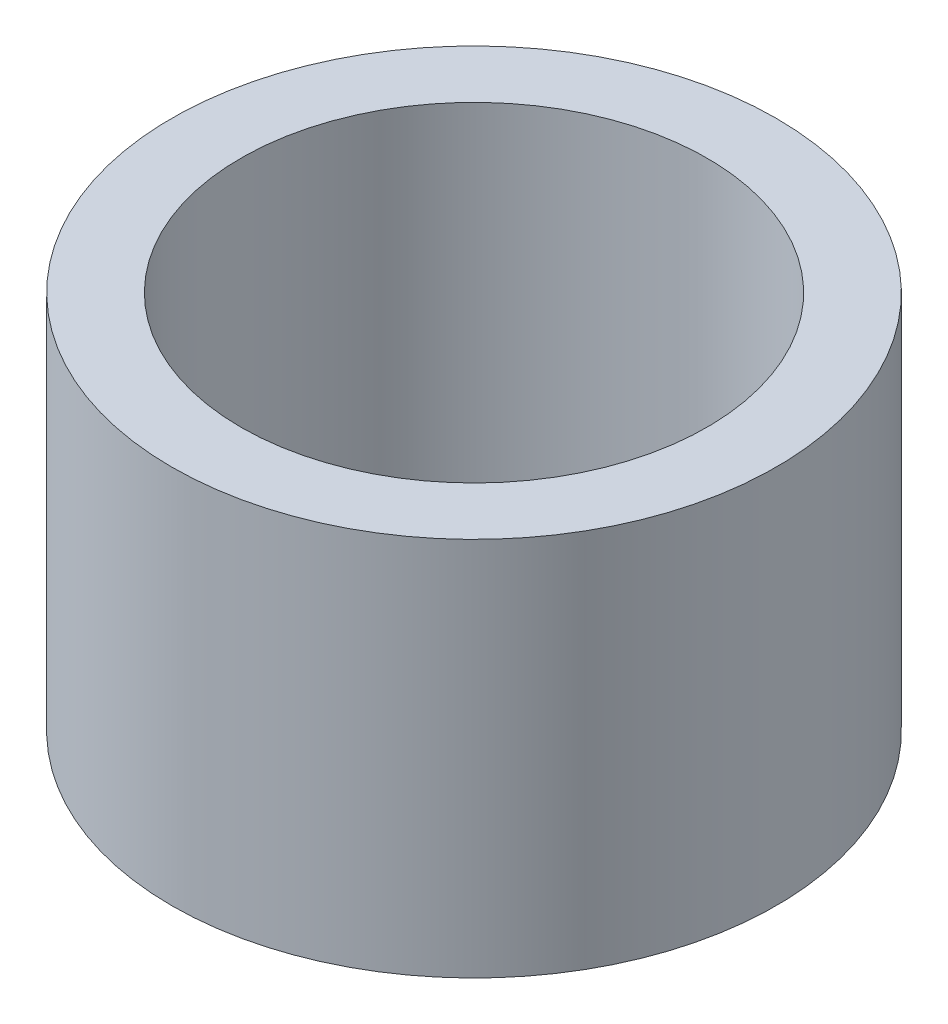
from build123d import *

# Parameters (mm, degrees)
SKETCH1_R           = 4.375
SKETCH1_R_2         = 3.375
BOSS_EXTRUDE1_DEPTH = 5.5


with BuildPart() as part:
    # Sketch1 → Boss-Extrude1 (new body)
    with BuildSketch(Plane(origin=(0, 0, 0), x_dir=(1, 0, 0), z_dir=(0, 1, 0))):
        Circle(SKETCH1_R)
        Circle(SKETCH1_R_2, mode=Mode.SUBTRACT)
    extrude(amount=BOSS_EXTRUDE1_DEPTH)


solid = part.part
